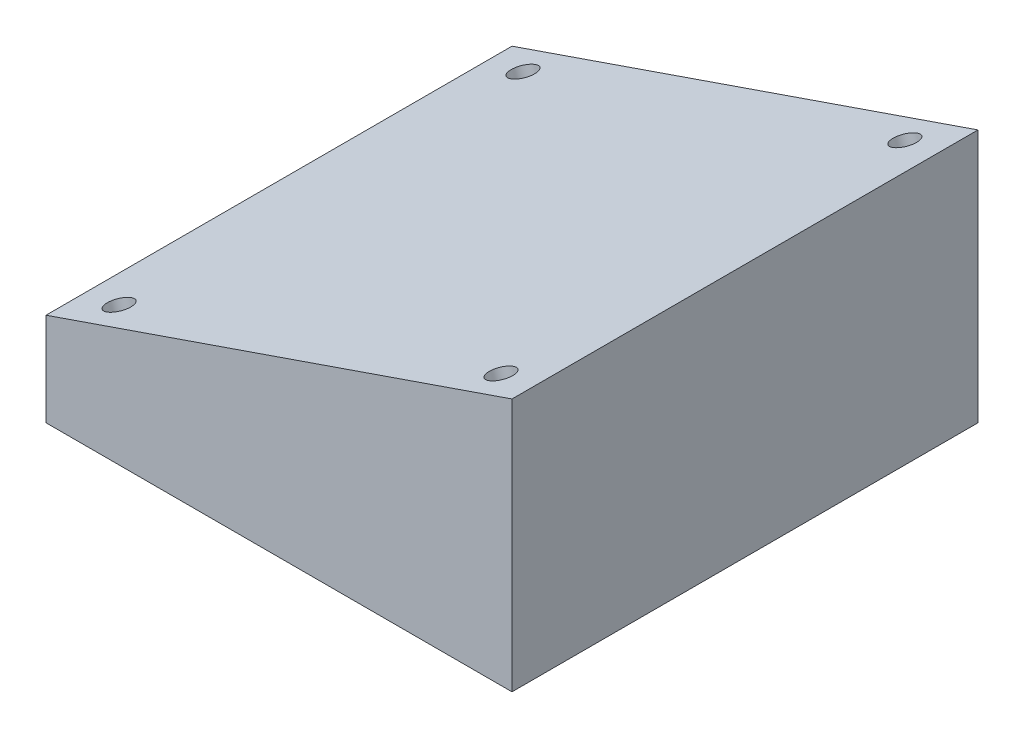
from build123d import *

# Parameters (mm, degrees)
ESBO_O1_W                            = 300
ESBO_O1_H                            = 300
RESSALTO_EXTRUS_O1_DEPTH             = 60
FURO_ROSCADO_DE_M16X2_01_D           = 14
FURO_ROSCADO_DE_M16X2_01_DEPTH       = 10
FURO_ROSCADO_DE_M16X2_01_TIP         = 4.206024333
RESSALTO_EXTRUS_O2_REACH             = 152
RESSALTO_EXTRUS_O2_DIRECTION_2_REACH = 152
FURO_ROSCADO_DE_M18X2_01_D           = 16
FURO_ROSCADO_DE_M18X2_01_DEPTH       = 18
FURO_ROSCADO_DE_M18X2_01_TIP         = 4.806884952


with BuildPart() as part:
    # Esboço1 → Ressalto-extrusão1 (new body)
    with BuildSketch(Plane(origin=(0, 0, 0), x_dir=(1, 0, 0), z_dir=(0, 1, 0))):
        Rectangle(ESBO_O1_W, ESBO_O1_H)
    extrude(amount=RESSALTO_EXTRUS_O1_DEPTH)

    # Furo roscado de M16x2.01
    with Locations(Plane(origin=(0, 0, 0), x_dir=(-1, 0, 0), z_dir=(0, -1, 0))):
        with Locations((55, -71), (-55, -71), (-55, 71), (55, 71)):
            Hole(FURO_ROSCADO_DE_M16X2_01_D / 2, depth=FURO_ROSCADO_DE_M16X2_01_DEPTH)
            with Locations((0, 0, -(FURO_ROSCADO_DE_M16X2_01_DEPTH + FURO_ROSCADO_DE_M16X2_01_TIP / 2))):  # 118° drill point
                Cone(0, FURO_ROSCADO_DE_M16X2_01_D / 2, FURO_ROSCADO_DE_M16X2_01_TIP, mode=Mode.SUBTRACT)

    # Ressalto-extrusão2: up to this face of the body (flat: up to its plane)
    ressalto_extrus_o2_end = Plane(part.part.faces().sort_by_distance((0, 30, 150))[0])
    # Esboço12 → Ressalto-extrusão2 (add, up to the picked face)
    with BuildSketch(Plane.XY, mode=Mode.PRIVATE) as ressalto_extrus_o2_sk1:
        Polygon((-150, 60), (150, 163.298283987), (150, 60), align=None)
    ressalto_extrus_o2_tool1 = split(extrude(ressalto_extrus_o2_sk1.sketch, amount=RESSALTO_EXTRUS_O2_REACH, mode=Mode.PRIVATE), bisect_by=ressalto_extrus_o2_end, keep=Keep.BOTH, mode=Mode.PRIVATE)
    add(ressalto_extrus_o2_tool1.solids().sort_by_distance((50, 94.432761, 0))[0])

    # Ressalto-extrusão2 direction 2: up to this face of the body (flat: up to its plane)
    ressalto_extrus_o2_direction_2_end = Plane(part.part.faces().sort_by_distance((0, 30, -150))[0])
    # Esboço12 → Ressalto-extrusão2 direction 2 (add, up to the picked face)
    with BuildSketch(Plane.XY, mode=Mode.PRIVATE) as ressalto_extrus_o2_direction_2_sk1:
        Polygon((-150, 60), (150, 163.298283987), (150, 60), align=None)
    ressalto_extrus_o2_direction_2_tool1 = split(extrude(ressalto_extrus_o2_direction_2_sk1.sketch, amount=-RESSALTO_EXTRUS_O2_DIRECTION_2_REACH, mode=Mode.PRIVATE), bisect_by=ressalto_extrus_o2_direction_2_end, keep=Keep.BOTH, mode=Mode.PRIVATE)
    add(ressalto_extrus_o2_direction_2_tool1.solids().sort_by_distance((50, 94.432761, 0))[0])

    # Furo roscado de M18x2.01
    with Locations(Plane(origin=(-34.369037739, 99.814933258, 0), x_dir=(0.945518576, 0.325568154, 0), z_dir=(-0.325568154, 0.945518576, 0))):
        with Locations((-93.650594894, 130), (166.349405106, 130), (166.349405106, -130), (-93.650594894, -130)):
            Hole(FURO_ROSCADO_DE_M18X2_01_D / 2, depth=FURO_ROSCADO_DE_M18X2_01_DEPTH)
            with Locations((0, 0, -(FURO_ROSCADO_DE_M18X2_01_DEPTH + FURO_ROSCADO_DE_M18X2_01_TIP / 2))):  # 118° drill point
                Cone(0, FURO_ROSCADO_DE_M18X2_01_D / 2, FURO_ROSCADO_DE_M18X2_01_TIP, mode=Mode.SUBTRACT)


solid = part.part
